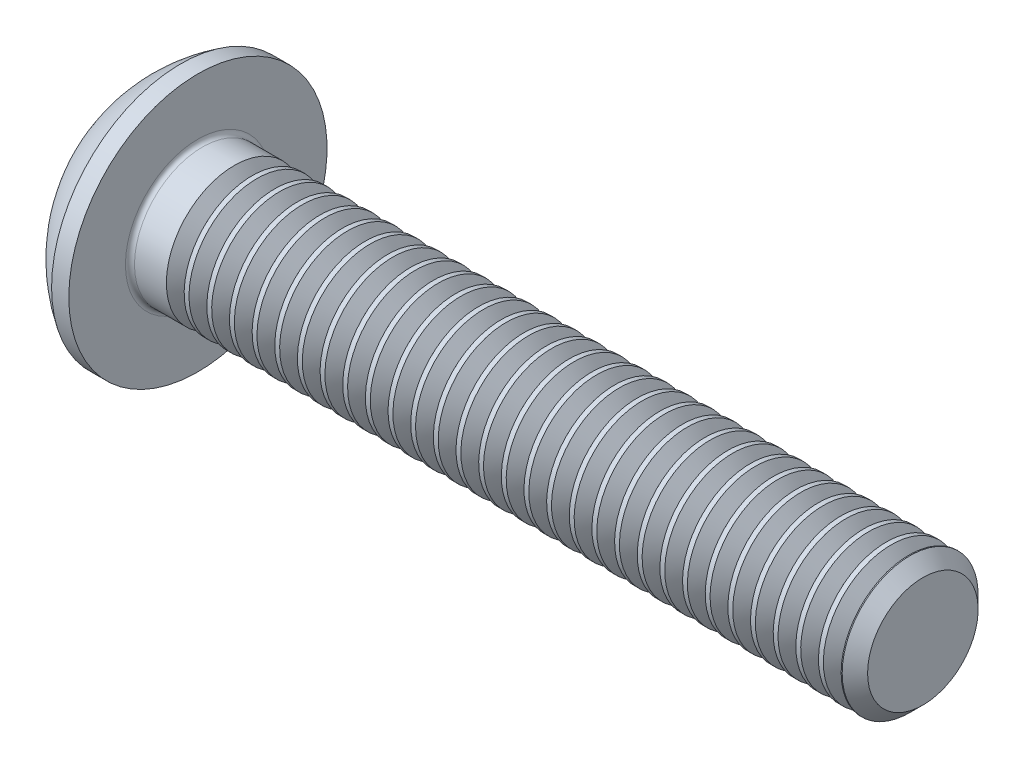
from build123d import *

# Parameters (mm, degrees)
FILLET1_R       = 0.1
HEX_2_DEPTH     = 1.04
THDSCHPAT_COUNT = 31
THDSCHPAT_PITCH = 0.5


with BuildPart() as part:
    # BodySke → BaseBody (revolve)
    with BuildSketch(Plane.XY):
        with BuildLine():
            Line((17.65, 0), (17.65, 1.2195))
            Line((17.65, 1.2195), (17.3695, 1.5))
            Line((17.3695, 1.5), (1.65, 1.5))
            Line((1.65, 1.5), (1.65, 2.85))
            Line((1.65, 2.85), (1.27, 2.85))
            ThreePointArc((1.27, 2.85), (0.53140404, 2.229827628), (0, 1.425))
            Line((0, 1.425), (0, 0))
            Line((0, 0), (17.65, 0))
        make_face()
    revolve(axis=Axis((0, 0, 0), (1, 0, 0)))

    # Fillet1
    fillet1_edges = [part.edges().sort_by_distance(p)[0] for p in [
        (1.65, -1.5, 0),
    ]]
    fillet(fillet1_edges, radius=FILLET1_R)

    # Sketch2 → PreBroach (revolve, cut)
    with BuildSketch(Plane.XY):
        Polygon((0, 1), (1.04, 1), (1.617350269, 0), (0, 0), align=None)
    revolve(axis=Axis((0, 0, 0), (1, 0, 0)), mode=Mode.SUBTRACT)

    # Sketch3 → Hex 2 (cut)
    with BuildSketch(Plane(origin=(0, 0, 0), x_dir=(0, 0, -1), z_dir=(1, 0, 0))):
        Polygon((-1, -0.577350269), (-1, 0.577350269), (0, 1.154700538), (1, 0.577350269), (1, -0.577350269), (0, -1.154700538), align=None)
    extrude(amount=HEX_2_DEPTH, mode=Mode.SUBTRACT)

    # ThdSchSke → ThreadSchematic (revolve, cut)
    with BuildSketch(Plane.XY):
        Polygon((2.65, -1.2195), (2.453591786, -1.5), (2.453591786, -1.875), (2.846408214, -1.875), (2.846408214, -1.5), align=None)
    threadschematic = revolve(axis=Axis((-3.175, 0, 0), (1, 0, 0)), mode=Mode.SUBTRACT)

    # ThdSchPat: ThreadSchematic ×31
    with Locations(*[(i * THDSCHPAT_PITCH, 0, 0) for i in range(1, THDSCHPAT_COUNT)]):
        add(threadschematic, mode=Mode.SUBTRACT)


solid = part.part
